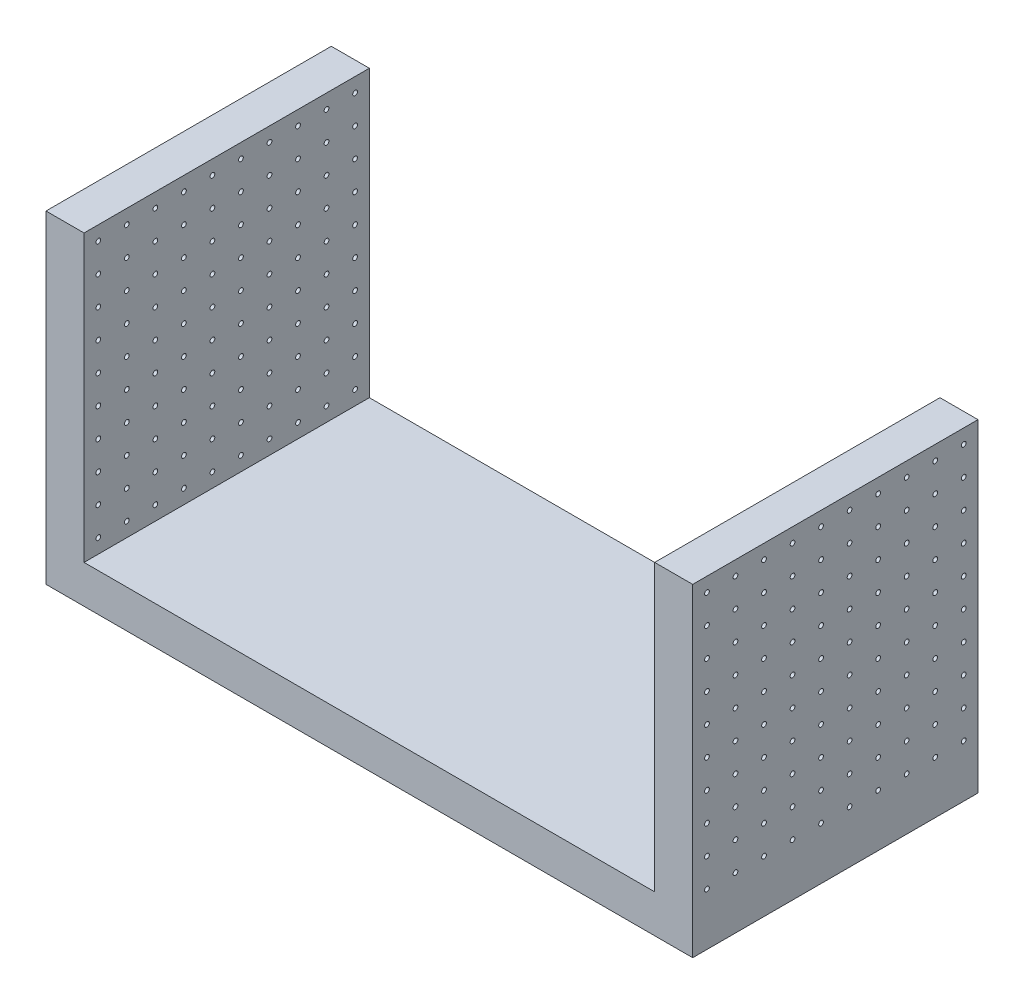
from build123d import *

# Parameters (mm, degrees)
SKETCH1_W                = 34
SKETCH1_H                = 17
BOSS_EXTRUDE1_DEPTH      = 7.5
BOSS_EXTRUDE1_DEPTH_BACK = 7.5
SKETCH2_W                = 30
SKETCH2_H                = 15
CUT_EXTRUDE1_DEPTH       = 15
SKETCH3_R                = 0.125
CUT_EXTRUDE2_DEPTH       = 34
LPATTERN1_COUNT          = 10
LPATTERN1_PITCH          = 1.5
LPATTERN1_COUNT_DIR2     = 10
LPATTERN1_PITCH_DIR2     = 1.5


with BuildPart() as part:
    # Sketch1 → Boss-Extrude1 (new body, two sides)
    with BuildSketch(Plane.XY) as boss_extrude1_sk:
        Rectangle(SKETCH1_W, SKETCH1_H)
    extrude(amount=BOSS_EXTRUDE1_DEPTH)
    extrude(boss_extrude1_sk.sketch, amount=-BOSS_EXTRUDE1_DEPTH_BACK)

    # Sketch2 → Cut-Extrude1 (cut)
    with BuildSketch(Plane.XY.offset(7.5)):
        with Locations((0, 1)):
            Rectangle(SKETCH2_W, SKETCH2_H)
    extrude(amount=-CUT_EXTRUDE1_DEPTH, mode=Mode.SUBTRACT)

    # Sketch3 → Cut-Extrude2 (cut)
    with BuildSketch(Plane(origin=(17, 0, 0), x_dir=(0, 0, -1), z_dir=(1, 0, 0))):
        with Locations((-6.75, 7.75)):
            Circle(SKETCH3_R)
    cut_extrude2 = extrude(amount=-CUT_EXTRUDE2_DEPTH, mode=Mode.SUBTRACT)

    # LPattern1: Cut-Extrude2 10 × 10
    with Locations(*[(0, -j * LPATTERN1_PITCH_DIR2, -i * LPATTERN1_PITCH) for i in range(LPATTERN1_COUNT) for j in range(LPATTERN1_COUNT_DIR2) if (i, j) != (0, 0)]):
        add(cut_extrude2, mode=Mode.SUBTRACT)


solid = part.part
